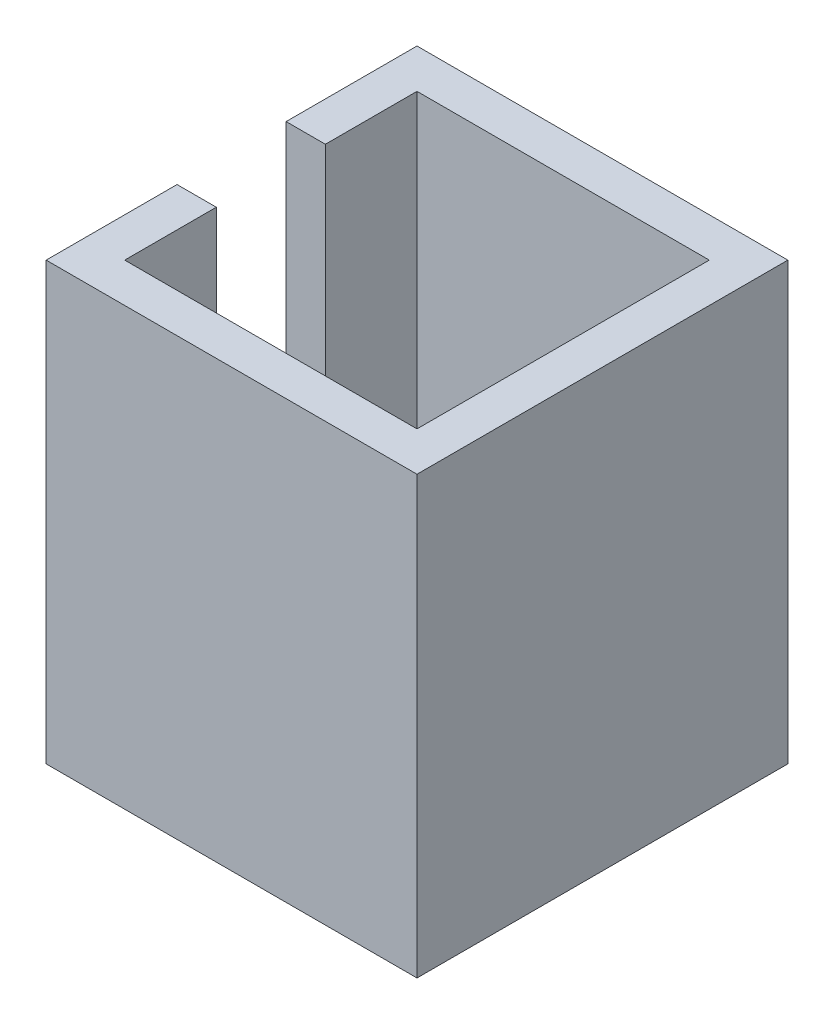
from build123d import *

# Parameters (mm, degrees)
SKETCH1_W                  = 17
SKETCH1_H                  = 17
BOSS_EXTRUDE1_DEPTH        = 20
SHELL1_T                   = -1.8
F_6_5_6_5_DIAMETER_HOLE1_D = 6.5
SKETCH5_W                  = 5
SKETCH5_H                  = 15.022252834
CUT_EXTRUDE1_DEPTH         = 4


with BuildPart() as part:
    # Sketch1 → Boss-Extrude1 (new body)
    with BuildSketch(Plane(origin=(0, 0, 0), x_dir=(1, 0, 0), z_dir=(0, 1, 0))):
        with Locations((8.5, 8.5)):
            Rectangle(SKETCH1_W, SKETCH1_H)
    extrude(amount=BOSS_EXTRUDE1_DEPTH)

    # Shell1
    shell1_openings = [part.faces().sort_by_distance(p)[0] for p in [
        (8.5, 20, -8.5),
    ]]
    offset(amount=SHELL1_T, openings=shell1_openings, kind=Kind.INTERSECTION)

    # Ø6.5 (6.5) Diameter Hole1 (through all)
    with Locations(Plane(origin=(0, 0, 0), x_dir=(-1, 0, 0), z_dir=(0, -1, 0))):
        with Locations((-8.5, 8.5)):
            Hole(F_6_5_6_5_DIAMETER_HOLE1_D / 2)

    # Sketch5 → Cut-Extrude1 (cut)
    with BuildSketch(Plane.ZY):
        with Locations((-8.5, 12.488873583)):
            Rectangle(SKETCH5_W, SKETCH5_H)
    extrude(amount=-CUT_EXTRUDE1_DEPTH, mode=Mode.SUBTRACT)


solid = part.part
